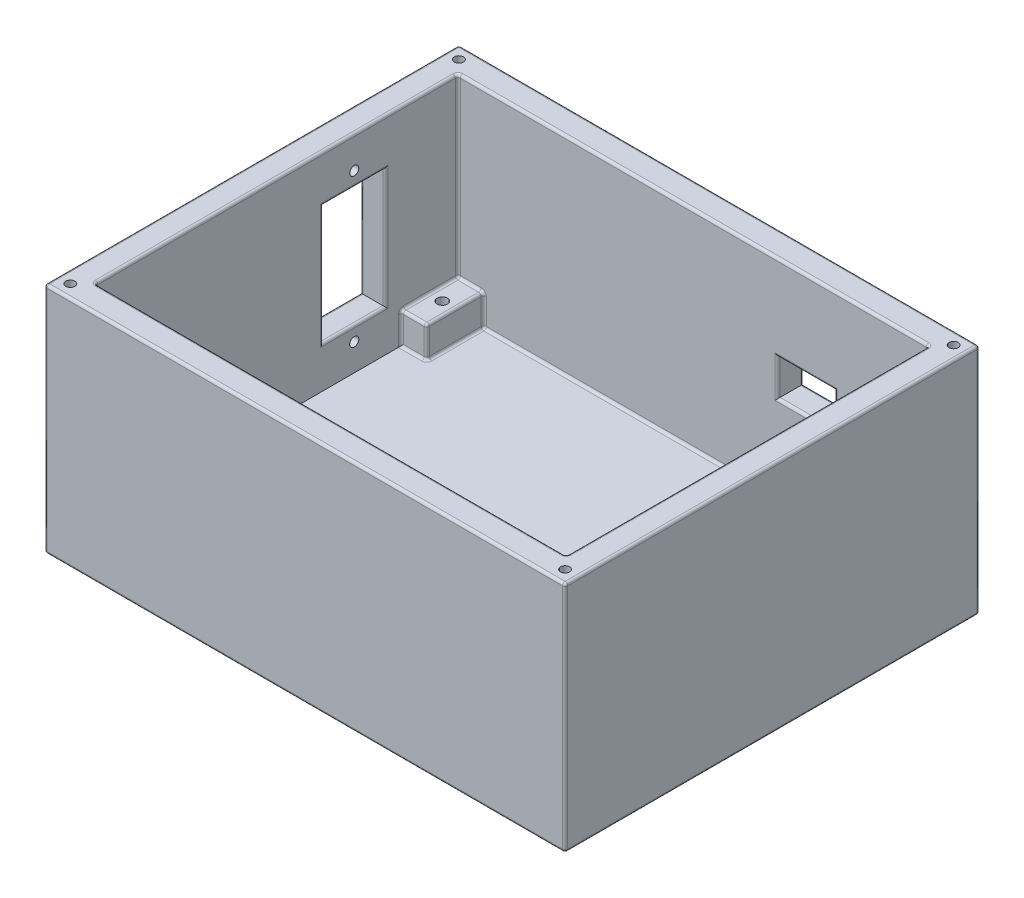
from build123d import *

# Parameters (mm, degrees)
SKETCH1_W                      = 100.5
SKETCH1_H                      = 80
BOSS_EXTRUDE1_DEPTH            = 45
SKETCH2_W                      = 90.9
SKETCH2_H                      = 70
CUT_EXTRUDE1_DEPTH             = 40
SKETCH3_W                      = 9
SKETCH3_H                      = 12
SKETCH3_H_2                    = 11
SKETCH3_W_2                    = 5
BOSS_EXTRUDE2_DEPTH            = 6
SKETCH4_R                      = 1
CUT_EXTRUDE2_DEPTH             = 8
CUT_EXTRUDE3_REACH             = 82
SKETCH5_W                      = 11
SKETCH5_H                      = 7
CUT_EXTRUDE3_DIRECTION_2_DEPTH = 1
SKETCH6_R                      = 0.875
CUT_EXTRUDE4_DEPTH             = 10
CUT_EXTRUDE5_REACH             = 102.5
SKETCH8_W                      = 12
SKETCH8_H                      = 23
SKETCH9_R                      = 0.875
CUT_EXTRUDE6_DEPTH             = 5
FILLET1_R                      = 0.5


with BuildPart() as part:
    # Sketch1 → Boss-Extrude1 (new body)
    with BuildSketch(Plane(origin=(0, 0, 0), x_dir=(1, 0, 0), z_dir=(0, 1, 0))):
        Rectangle(SKETCH1_W, SKETCH1_H)
    extrude(amount=BOSS_EXTRUDE1_DEPTH)

    # Sketch2 → Cut-Extrude1 (cut)
    with BuildSketch(Plane(origin=(0, 45, 0), x_dir=(1, 0, 0), z_dir=(0, 1, 0))):
        Rectangle(SKETCH2_W, SKETCH2_H)
    extrude(amount=-CUT_EXTRUDE1_DEPTH, mode=Mode.SUBTRACT)

    # Sketch3 → Boss-Extrude2 (add)
    with BuildSketch(Plane(origin=(0, 5, 0), x_dir=(1, 0, 0), z_dir=(0, 1, 0))):
        with Locations((40.95, 29)):
            Rectangle(SKETCH3_W, SKETCH3_H)
        with Locations((40.95, -29.5)):
            Rectangle(SKETCH3_W, SKETCH3_H_2)
        with Locations((-42.95, -29.5)):
            Rectangle(SKETCH3_W_2, SKETCH3_H_2)
        with Locations((-42.95, 29.5)):
            Rectangle(SKETCH3_W_2, SKETCH3_H_2)
    extrude(amount=BOSS_EXTRUDE2_DEPTH)

    # Sketch4 → Cut-Extrude2 (cut)
    with BuildSketch(Plane(origin=(0, 11, 0), x_dir=(1, 0, 0), z_dir=(0, 1, 0))):
        with Locations((-42.95, -29.5)):
            Circle(SKETCH4_R)
        with Locations((40.95, -29.5)):
            Circle(SKETCH4_R)
        with Locations((40.95, 29)):
            Circle(SKETCH4_R)
        with Locations((-42.95, 29.5)):
            Circle(SKETCH4_R)
    extrude(amount=-CUT_EXTRUDE2_DEPTH, mode=Mode.SUBTRACT)

    # Sketch5 → Cut-Extrude3 (cut, up to next)
    with BuildSketch(Plane(origin=(0, 0, -40), x_dir=(-1, 0, 0), z_dir=(0, 0, -1)), mode=Mode.PRIVATE) as cut_extrude3_sk1:
        with Locations((-21.75, 25)):
            Rectangle(SKETCH5_W, SKETCH5_H)
    cut_extrude3_tool1 = extrude(cut_extrude3_sk1.sketch, amount=-CUT_EXTRUDE3_REACH, mode=Mode.PRIVATE) & part.part
    add(cut_extrude3_tool1.solids().sort_by_distance((21.75, 25, -40))[0], mode=Mode.SUBTRACT)

    # Sketch5 → Cut-Extrude3 direction 2 (cut)
    with BuildSketch(Plane(origin=(0, 0, -40), x_dir=(-1, 0, 0), z_dir=(0, 0, -1))):
        with Locations((-21.75, 25)):
            Rectangle(SKETCH5_W, SKETCH5_H)
    extrude(amount=CUT_EXTRUDE3_DIRECTION_2_DEPTH, mode=Mode.SUBTRACT)

    # Sketch6 → Cut-Extrude4 (cut)
    with BuildSketch(Plane(origin=(0, 45, 0), x_dir=(1, 0, 0), z_dir=(0, 1, 0))):
        with Locations((-47.75, 37.5)):
            Circle(SKETCH6_R)
        with Locations((-47.75, -37.5)):
            Circle(SKETCH6_R)
        with Locations((47.75, -37.5)):
            Circle(SKETCH6_R)
        with Locations((47.75, 37.5)):
            Circle(SKETCH6_R)
    extrude(amount=-CUT_EXTRUDE4_DEPTH, mode=Mode.SUBTRACT)

    # Sketch8 → Cut-Extrude5 (cut, up to next)
    with BuildSketch(Plane.ZY.offset(50.25), mode=Mode.PRIVATE) as cut_extrude5_sk1:
        with Locations((-15, 24.5)):
            Rectangle(SKETCH8_W, SKETCH8_H)
    cut_extrude5_tool1 = extrude(cut_extrude5_sk1.sketch, amount=-CUT_EXTRUDE5_REACH, mode=Mode.PRIVATE) & part.part
    add(cut_extrude5_tool1.solids().sort_by_distance((-50.25, 24.5, -15))[0], mode=Mode.SUBTRACT)

    # Sketch9 → Cut-Extrude6 (cut)
    with BuildSketch(Plane.ZY.offset(50.25)):
        with Locations((-15, 38.8)):
            Circle(SKETCH9_R)
        with Locations((-15, 10.2)):
            Circle(SKETCH9_R)
    extrude(amount=-CUT_EXTRUDE6_DEPTH, mode=Mode.SUBTRACT)

    # Fillet1
    fillet1_edges = [part.edges().sort_by_distance(p)[0] for p in [
        (-50.25, 45, 0),
        (21.75, 21.5, -35),
        (27.25, 25, -35),
        (21.75, 28.5, -35),
        (16.25, 25, -35),
        (0, 45, 40),
        (-50.25, 24.5, -21),
        (-50.25, 13, -15),
        (-50.25, 24.5, -9),
        (-50.25, 36, -15),
        (-45.45, 13, -15),
        (-45.45, 24.5, -21),
        (-45.45, 36, -15),
        (-45.45, 24.5, -9),
        (45.45, 45, 0),
        (0, 45, -35),
        (-45.45, 45, 0),
        (0, 45, 35),
        (-2, 5, -35),
        (45.45, 28, -35),
        (45.45, 8, -23),
        (36.45, 5, -29),
        (36.45, 8, -35),
        (40.95, 5, -23),
        (36.45, 8, -23),
        (45.45, 11, -29),
        (40.95, 11, -35),
        (36.45, 11, -29),
        (40.95, 11, -23),
        (45.45, 28, 35),
        (50.25, 45, 0),
        (45.45, 5, 0.5),
        (40.95, 5, 24),
        (45.45, 8, 24),
        (36.45, 5, 29.5),
        (36.45, 8, 24),
        (36.45, 8, 35),
        (45.45, 11, 29.5),
        (40.95, 11, 24),
        (0, 0, 40),
        (36.45, 11, 29.5),
        (40.95, 11, 35),
        (-50.25, 0, 0),
        (-45.45, 28, 35),
        (0, 0, -40),
        (-2, 5, 35),
        (-45.45, 8, 24),
        (-40.45, 5, 29.5),
        (-40.45, 8, 35),
        (-42.95, 5, 24),
        (-45.45, 11, 29.5),
        (50.25, 0, 0),
        (-42.95, 11, 35),
        (-40.45, 11, 29.5),
        (-42.95, 11, 24),
        (-45.45, 28, -35),
        (-42.95, 5, -24),
        (-45.45, 8, -24),
        (-40.45, 5, -29.5),
        (-40.45, 8, -24),
        (-40.45, 8, -35),
        (-45.45, 11, -29.5),
        (-42.95, 11, -24),
        (-40.45, 11, -29.5),
        (0, 45, -40),
        (-42.95, 11, -35),
        (50.25, 22.5, 40),
        (-50.25, 22.5, 40),
        (-50.25, 22.5, -40),
        (50.25, 22.5, -40),
        (21.75, 28.5, -40),
        (16.25, 25, -40),
        (21.75, 21.5, -40),
        (27.25, 25, -40),
    ]]
    fillet(fillet1_edges, radius=FILLET1_R)


solid = part.part
